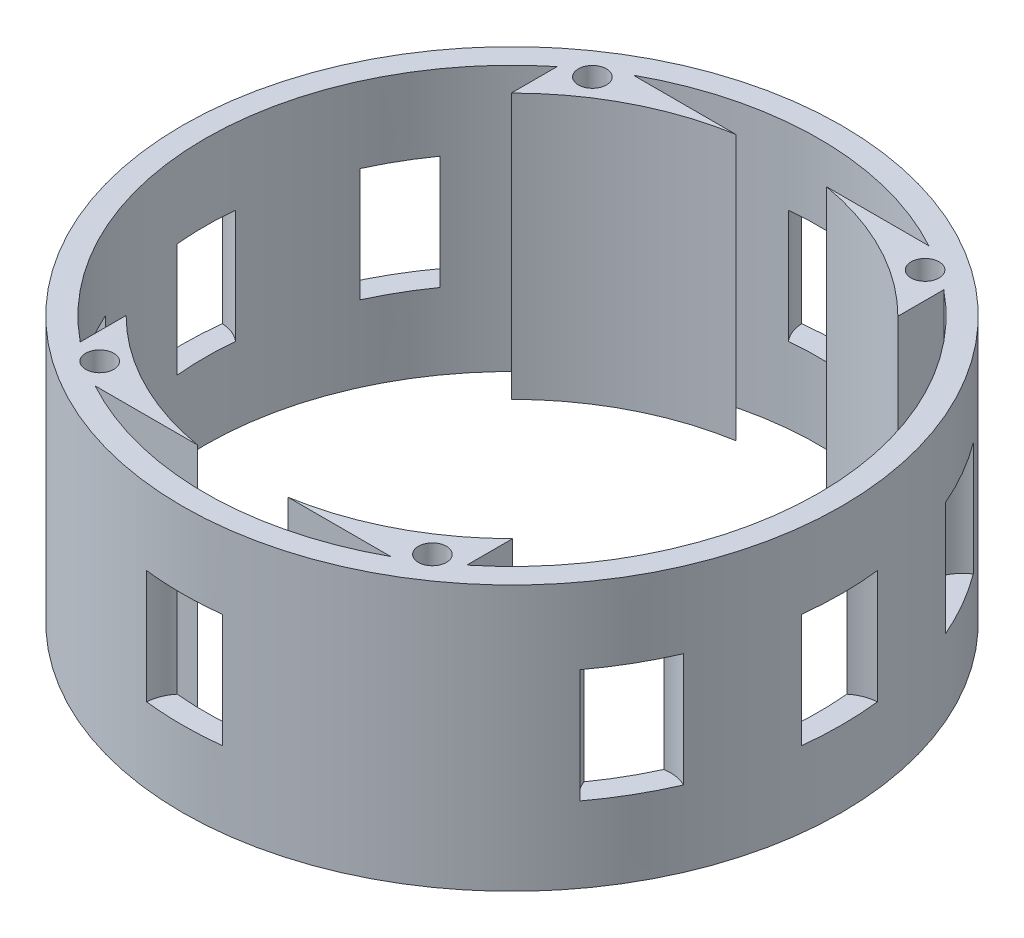
from build123d import *

# Parameters (mm, degrees)
SKETCH1_R               = 43.5
SKETCH1_R_2             = 40.5
BOSS_EXTRUDE1_DEPTH     = 35
SKETCH2_R               = 1.85
CUT_EXTRUDE1_DEPTH      = 15
CUT_EXTRUDE3_DEPTH      = 7.5
CUT_EXTRUDE3_DEPTH_BACK = 7.5


with BuildPart() as part:
    # Sketch1 → Boss-Extrude1 (new body)
    with BuildSketch(Plane(origin=(0, 0, 0), x_dir=(1, 0, 0), z_dir=(0, 1, 0))):
        Circle(SKETCH1_R)
        Circle(SKETCH1_R_2, mode=Mode.SUBTRACT)
        with BuildLine():
            Line((-25.5, -25.411611519), (-25.5, -31.464265445))
            ThreePointArc((-25.5, -31.464265445), (-22.587110133, -33.616550327), (-19.49358869, -35.5))
            Line((-19.49358869, -35.5), (-5.979130372, -35.5))
            ThreePointArc((-5.979130372, -35.5), (-16.528091474, -31.981591459), (-25.5, -25.411611519))
        make_face()
        with BuildLine():
            Line((5.979130372, -35.5), (19.49358869, -35.5))
            ThreePointArc((19.49358869, -35.5), (22.587110133, -33.616550327), (25.5, -31.464265445))
            Line((25.5, -31.464265445), (25.5, -25.411611519))
            ThreePointArc((25.5, -25.411611519), (16.528091474, -31.981591459), (5.979130372, -35.5))
        make_face()
        with BuildLine():
            ThreePointArc((25.5, 31.464265445), (22.587110133, 33.616550327), (19.49358869, 35.5))
            Line((19.49358869, 35.5), (5.979130372, 35.5))
            ThreePointArc((5.979130372, 35.5), (16.528091474, 31.981591459), (25.5, 25.411611519))
            Line((25.5, 25.411611519), (25.5, 31.464265445))
        make_face()
        with BuildLine():
            ThreePointArc((-19.49358869, 35.5), (-22.587110133, 33.616550327), (-25.5, 31.464265445))
            Line((-25.5, 31.464265445), (-25.5, 25.411611519))
            ThreePointArc((-25.5, 25.411611519), (-16.528091474, 31.981591459), (-5.979130372, 35.5))
            Line((-5.979130372, 35.5), (-19.49358869, 35.5))
        make_face()
    extrude(amount=BOSS_EXTRUDE1_DEPTH)

    # Sketch2 → Cut-Extrude1 (cut)
    with BuildSketch(Plane(origin=(0, 35, 0), x_dir=(1, 0, 0), z_dir=(0, 1, 0))):
        with Locations((-22, 32.606393643)):
            Circle(SKETCH2_R)
        with Locations((22, 32.5)):
            Circle(SKETCH2_R)
        with Locations((22, -32.5)):
            Circle(SKETCH2_R)
        with Locations((-22, -32.393606357)):
            Circle(SKETCH2_R)
    extrude(amount=-CUT_EXTRUDE1_DEPTH, mode=Mode.SUBTRACT)

    # Sketch6 → Cut-Extrude3 (cut, two sides)
    with BuildSketch(Plane(origin=(0, 17.5, 0), x_dir=(1, 0, 0), z_dir=(0, 1, 0))) as cut_extrude3_sk:
        with BuildLine():
            ThreePointArc((-40.316091954, 3.855221077), (-41.673709906, 4.654531608), (-43.212643678, 4.991735805))
            ThreePointArc((-43.212643678, 4.991735805), (-43.5, 0), (-43.212643678, -4.991735805))
            ThreePointArc((-43.212643678, -4.991735805), (-41.673709906, -4.654531608), (-40.316091954, -3.855221077))
            ThreePointArc((-40.316091954, -3.855221077), (-40.5, 0), (-40.316091954, 3.855221077))
        make_face()
        with BuildLine():
            ThreePointArc((-39.919115092, -17.283351823), (-37.672105065, -21.75), (-34.927379288, -25.929291855))
            ThreePointArc((-34.927379288, -25.929291855), (-33.763225644, -24.867797568), (-32.987149275, -23.496765367))
            ThreePointArc((-32.987149275, -23.496765367), (-35.074028853, -20.25), (-36.842370352, -16.819326587))
            ThreePointArc((-36.842370352, -16.819326587), (-38.417757252, -16.805912337), (-39.919115092, -17.283351823))
        make_face()
        with BuildLine():
            ThreePointArc((4.991735805, -43.212643678), (4.654531608, -41.673709906), (3.855221077, -40.316091954))
            ThreePointArc((3.855221077, -40.316091954), (0, -40.5), (-3.855221077, -40.316091954))
            ThreePointArc((-3.855221077, -40.316091954), (-4.654531608, -41.673709906), (-4.991735805, -43.212643678))
            ThreePointArc((-4.991735805, -43.212643678), (0, -43.5), (4.991735805, -43.212643678))
        make_face()
        with BuildLine():
            ThreePointArc((34.927379288, -25.929291855), (37.672105065, -21.75), (39.919115092, -17.283351823))
            ThreePointArc((39.919115092, -17.283351823), (38.417757252, -16.805912337), (36.842370352, -16.819326587))
            ThreePointArc((36.842370352, -16.819326587), (35.074028853, -20.25), (32.987149275, -23.496765367))
            ThreePointArc((32.987149275, -23.496765367), (33.763225644, -24.867797568), (34.927379288, -25.929291855))
        make_face()
        with BuildLine():
            ThreePointArc((40.316091954, -3.855221077), (40.5, 0), (40.316091954, 3.855221077))
            ThreePointArc((40.316091954, 3.855221077), (41.673709906, 4.654531608), (43.212643678, 4.991735805))
            ThreePointArc((43.212643678, 4.991735805), (43.5, 0), (43.212643678, -4.991735805))
            ThreePointArc((43.212643678, -4.991735805), (41.673709906, -4.654531608), (40.316091954, -3.855221077))
        make_face()
        with BuildLine():
            ThreePointArc((39.919115092, 17.283351823), (37.672105065, 21.75), (34.927379288, 25.929291855))
            ThreePointArc((34.927379288, 25.929291855), (33.763225644, 24.867797568), (32.987149275, 23.496765367))
            ThreePointArc((32.987149275, 23.496765367), (35.074028853, 20.25), (36.842370352, 16.819326587))
            ThreePointArc((36.842370352, 16.819326587), (38.417757252, 16.805912337), (39.919115092, 17.283351823))
        make_face()
        with BuildLine():
            ThreePointArc((3.855221077, 40.316091954), (0, 40.5), (-3.855221077, 40.316091954))
            ThreePointArc((-3.855221077, 40.316091954), (-4.654531608, 41.673709906), (-4.991735805, 43.212643678))
            ThreePointArc((-4.991735805, 43.212643678), (0, 43.5), (4.991735805, 43.212643678))
            ThreePointArc((4.991735805, 43.212643678), (4.654531608, 41.673709906), (3.855221077, 40.316091954))
        make_face()
        with BuildLine():
            ThreePointArc((-34.927379288, 25.929291855), (-37.672105065, 21.75), (-39.919115092, 17.283351823))
            ThreePointArc((-39.919115092, 17.283351823), (-38.417757252, 16.805912337), (-36.842370352, 16.819326587))
            ThreePointArc((-36.842370352, 16.819326587), (-35.074028853, 20.25), (-32.987149275, 23.496765367))
            ThreePointArc((-32.987149275, 23.496765367), (-33.763225644, 24.867797568), (-34.927379288, 25.929291855))
        make_face()
    extrude(amount=CUT_EXTRUDE3_DEPTH, mode=Mode.SUBTRACT)
    extrude(cut_extrude3_sk.sketch, amount=-CUT_EXTRUDE3_DEPTH_BACK, mode=Mode.SUBTRACT)


solid = part.part
